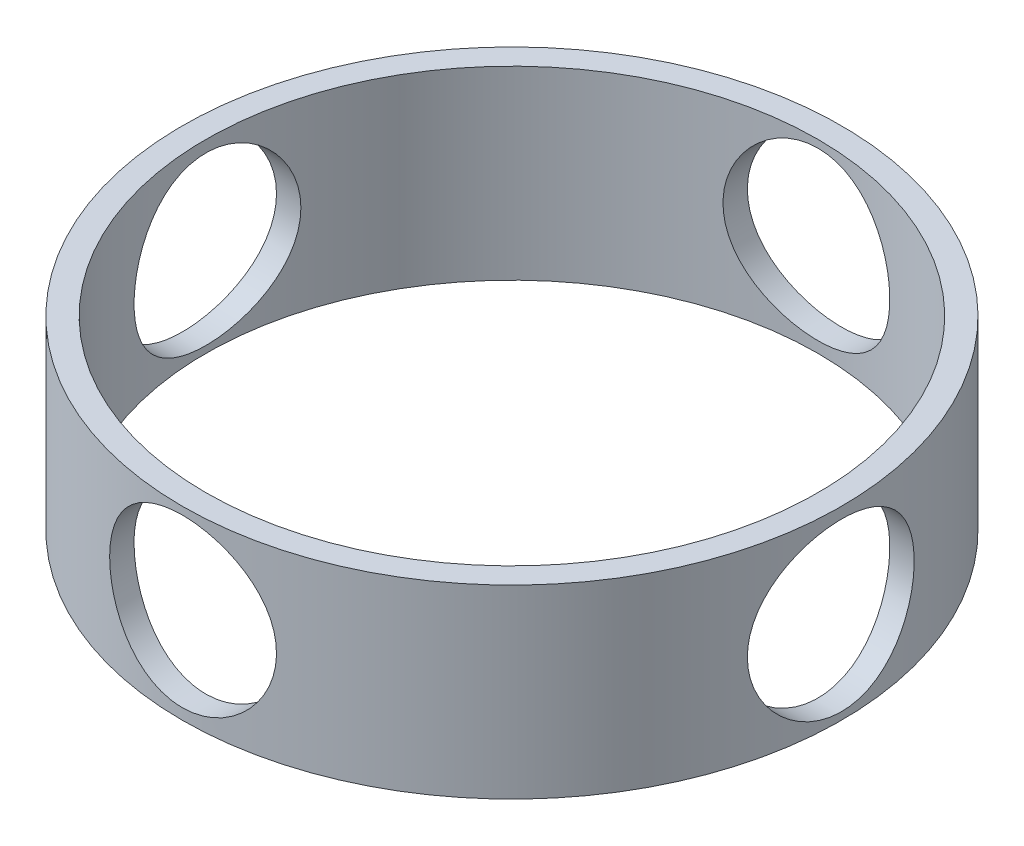
from build123d import *

# Parameters (mm, degrees)
SKETCH1_R           = 88.9
BOSS_EXTRUDE1_DEPTH = 50
SKETCH2_R           = 82.55
CUT_EXTRUDE4_DEPTH  = 74
SKETCH12_R          = 22.5
CUT_EXTRUDE5_DEPTH  = 115.64
SKETCH13_R          = 22.5
CUT_EXTRUDE6_DEPTH  = 115.64
SKETCH14_R          = 22.5
CUT_EXTRUDE7_DEPTH  = 99.64
CUT_EXTRUDE8_START  = 137.64
SKETCH15_R          = 22.5
CUT_EXTRUDE8_DEPTH  = 137.64


with BuildPart() as part:
    # Sketch1 → Boss-Extrude1 (new body)
    with BuildSketch(Plane(origin=(0, 0, 0), x_dir=(1, 0, 0), z_dir=(0, 1, 0))):
        Circle(SKETCH1_R)
    extrude(amount=BOSS_EXTRUDE1_DEPTH)

    # Sketch2 → Cut-Extrude4 (cut)
    with BuildSketch(Plane(origin=(0, 0, 0), x_dir=(1, 0, 0), z_dir=(0, 1, 0))):
        Circle(SKETCH2_R)
    extrude(amount=CUT_EXTRUDE4_DEPTH, mode=Mode.SUBTRACT)

    # Sketch12 → Cut-Extrude5 (cut)
    with BuildSketch(Plane(origin=(0, 0, 0), x_dir=(0, 0, -1), z_dir=(1, 0, 0))):
        with Locations((0, 24.336091646)):
            Circle(SKETCH12_R)
    extrude(amount=-CUT_EXTRUDE5_DEPTH, mode=Mode.SUBTRACT)

    # Sketch13 → Cut-Extrude6 (cut)
    with BuildSketch(Plane.XY):
        with Locations((0, 25.450721797)):
            Circle(SKETCH13_R)
    extrude(amount=-CUT_EXTRUDE6_DEPTH, mode=Mode.SUBTRACT)

    # Sketch14 → Cut-Extrude7 (cut)
    with BuildSketch(Plane(origin=(0, 0, 0), x_dir=(0, 0, -1), z_dir=(1, 0, 0))):
        with Locations((0, 24.521863338)):
            Circle(SKETCH14_R)
    extrude(amount=CUT_EXTRUDE7_DEPTH, mode=Mode.SUBTRACT)

    # Sketch15 → Cut-Extrude8 (cut)
    with BuildSketch(Plane.XY.offset(CUT_EXTRUDE8_START)):
        with Locations((0, 25.450721797)):
            Circle(SKETCH15_R)
    extrude(amount=-CUT_EXTRUDE8_DEPTH, mode=Mode.SUBTRACT)


solid = part.part
